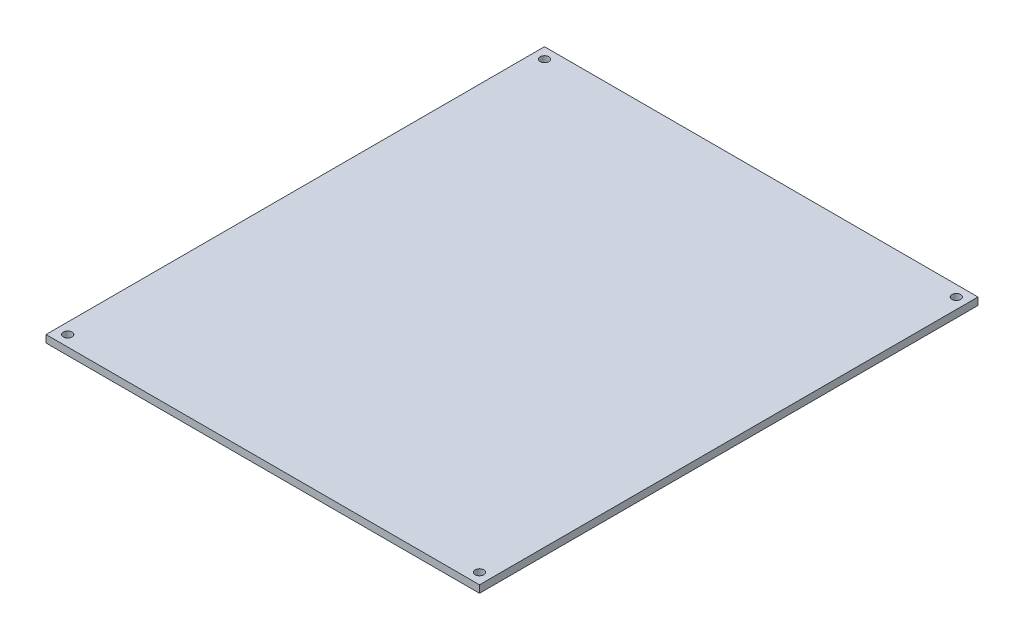
from build123d import *

# Parameters (mm, degrees)
SKETCH1_W           = 100
SKETCH1_H           = 115
BOSS_EXTRUDE1_DEPTH = 1.7
SKETCH2_R           = 1
CUT_EXTRUDE1_DEPTH  = 21.7


with BuildPart() as part:
    # Sketch1 → Boss-Extrude1 (new body)
    with BuildSketch(Plane(origin=(0, 0, 0), x_dir=(1, 0, 0), z_dir=(0, 1, 0))):
        Rectangle(SKETCH1_W, SKETCH1_H)
    extrude(amount=BOSS_EXTRUDE1_DEPTH)

    # Sketch2 → Cut-Extrude1 (cut)
    with BuildSketch(Plane.XZ):
        with Locations((47.5, 55)):
            Circle(SKETCH2_R)
        with Locations((-47.5, 55)):
            Circle(SKETCH2_R)
        with Locations((-47.5, -55)):
            Circle(SKETCH2_R)
        with Locations((47.5, -55)):
            Circle(SKETCH2_R)
    extrude(amount=-CUT_EXTRUDE1_DEPTH, mode=Mode.SUBTRACT)


solid = part.part
